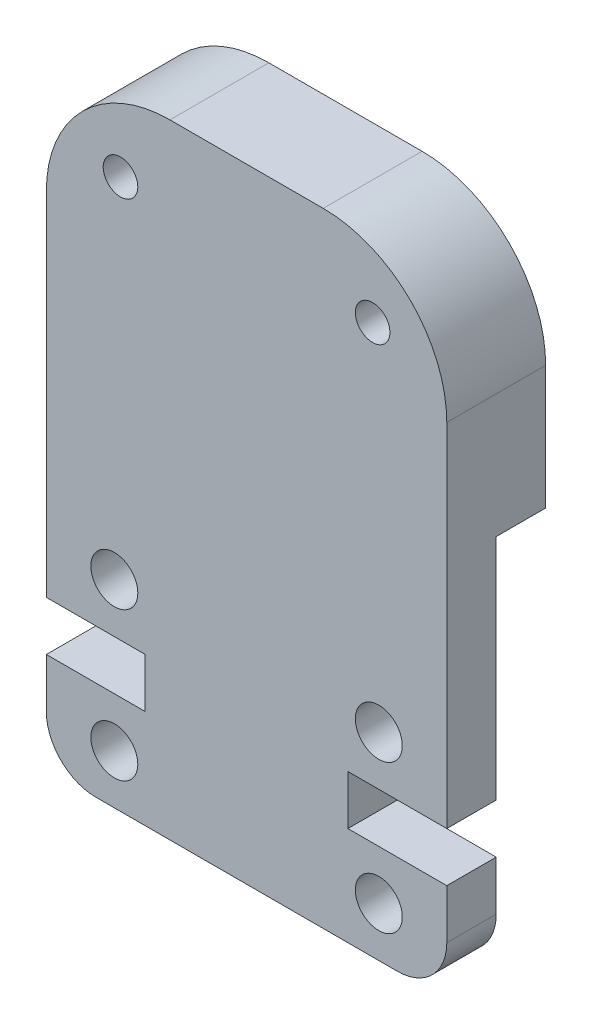
from build123d import *

# Parameters (mm, degrees)
SKETCH1_R           = 0.95
SKETCH1_R_2         = 0.7
BOSS_EXTRUDE1_DEPTH = 4
SKETCH2_W           = 16.2
SKETCH2_H           = 15.23
CUT_EXTRUDE1_DEPTH  = 2


with BuildPart() as part:
    # Sketch1 → Boss-Extrude1 (new body)
    with BuildSketch(Plane.XY):
        with BuildLine():
            Line((2, 0), (14.2, 0))
            ThreePointArc((14.2, 0), (15.614213562, 0.585786438), (16.2, 2))
            Line((16.2, 2), (16.2, 4))
            Line((16.2, 4), (12.2, 4))
            Line((12.2, 4), (12.2, 6))
            Line((12.2, 6), (16.2, 6))
            Line((16.2, 6), (16.2, 20.23))
            ThreePointArc((16.2, 20.23), (14.735533906, 23.765533906), (11.2, 25.23))
            Line((11.2, 25.23), (5, 25.23))
            ThreePointArc((5, 25.23), (1.464466094, 23.765533906), (0, 20.23))
            Line((0, 20.23), (0, 6))
            Line((0, 6), (4, 6))
            Line((4, 6), (4, 4))
            Line((4, 4), (0, 4))
            Line((0, 4), (0, 2))
            ThreePointArc((0, 2), (0.585786438, 0.585786438), (2, 0))
        make_face()
        with Locations((13.45, 2)):
            Circle(SKETCH1_R, mode=Mode.SUBTRACT)
        with Locations((13.2, 22.23)):
            Circle(SKETCH1_R_2, mode=Mode.SUBTRACT)
        with Locations((2.75, 8)):
            Circle(SKETCH1_R, mode=Mode.SUBTRACT)
        with Locations((13.45, 8)):
            Circle(SKETCH1_R, mode=Mode.SUBTRACT)
        with Locations((3, 22.23)):
            Circle(SKETCH1_R_2, mode=Mode.SUBTRACT)
        with Locations((2.75, 2)):
            Circle(SKETCH1_R, mode=Mode.SUBTRACT)
    extrude(amount=BOSS_EXTRUDE1_DEPTH)

    # Sketch2 → Cut-Extrude1 (cut)
    with BuildSketch(Plane.XY):
        with Locations((8.1, 7.615)):
            Rectangle(SKETCH2_W, SKETCH2_H)
    extrude(amount=CUT_EXTRUDE1_DEPTH, mode=Mode.SUBTRACT)


solid = part.part
